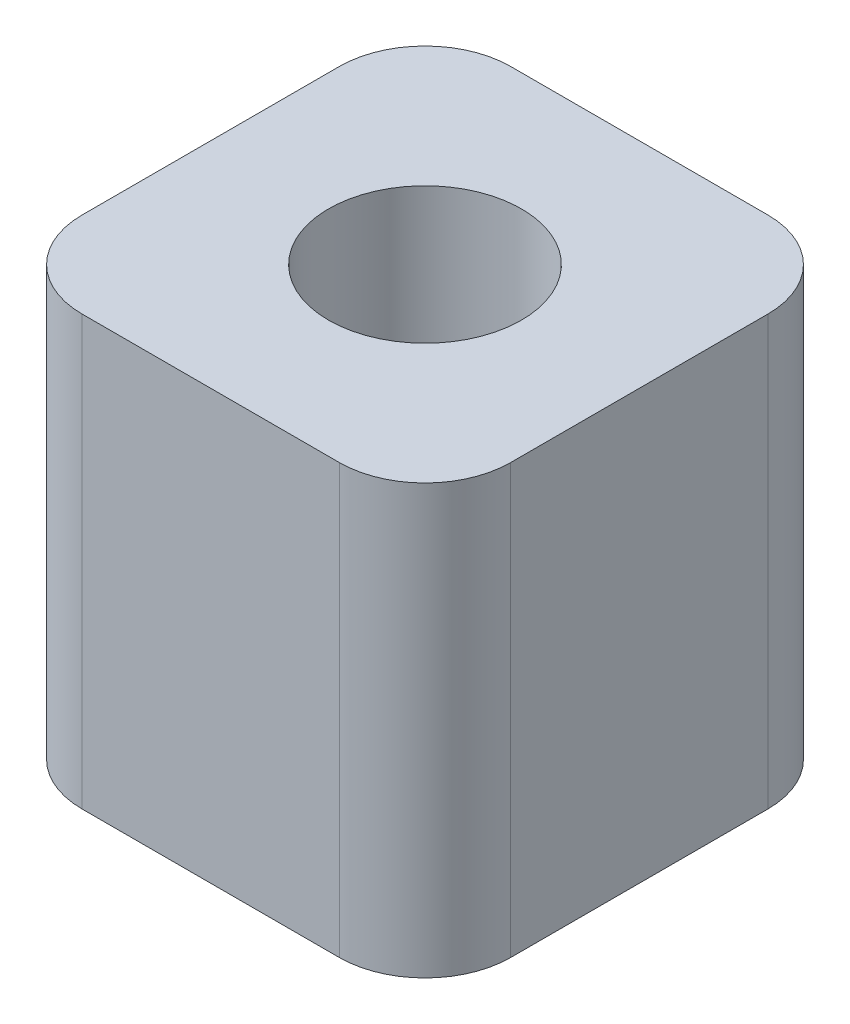
from build123d import *

# Parameters (mm, degrees)
SKETCH1_W           = 10
SKETCH1_H           = 10
SKETCH1_R           = 2.25
BOSS_EXTRUDE1_DEPTH = 10
FILLET1_R           = 2


with BuildPart() as part:
    # Sketch1 → Boss-Extrude1 (new body)
    with BuildSketch(Plane(origin=(0, 0, 0), x_dir=(1, 0, 0), z_dir=(0, 1, 0))):
        Rectangle(SKETCH1_W, SKETCH1_H)
        Circle(SKETCH1_R, mode=Mode.SUBTRACT)
    extrude(amount=BOSS_EXTRUDE1_DEPTH)

    # Fillet1
    fillet1_edges = [part.edges().sort_by_distance(p)[0] for p in [
        (5, 5, 5),
        (-5, 5, 5),
        (-5, 5, -5),
        (5, 5, -5),
    ]]
    fillet(fillet1_edges, radius=FILLET1_R)


solid = part.part
